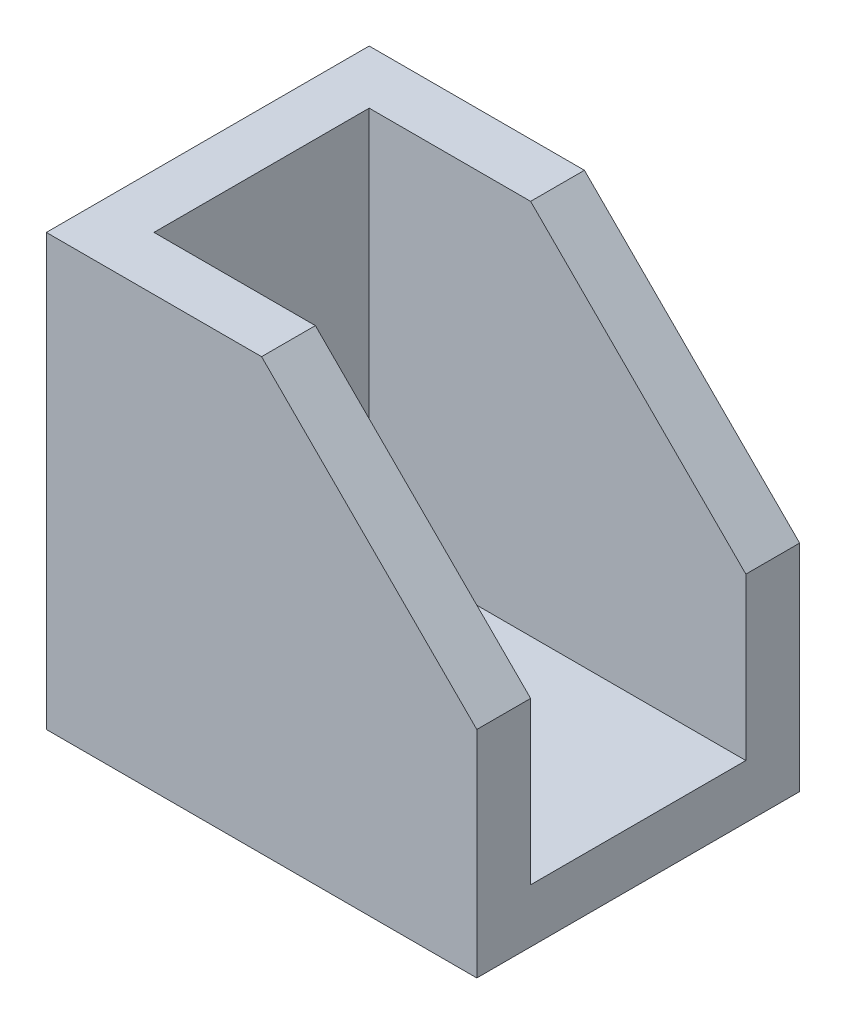
from build123d import *

# Parameters (mm, degrees)
BOSS_EXTRUDE1_DEPTH = 15
SKETCH2_W           = 10
SKETCH2_H           = 2.5
SKETCH2_H_2         = 7.5
CUT_EXTRUDE2_DEPTH  = 17.5


with BuildPart() as part:
    # Sketch1 → Boss-Extrude1 (new body)
    with BuildSketch(Plane.XY):
        Polygon((0, 0), (0, 20), (10, 20), (20, 10), (20, 0), align=None)
    extrude(amount=BOSS_EXTRUDE1_DEPTH)

    # Sketch2 → Cut-Extrude2 (cut)
    with BuildSketch(Plane(origin=(20, 0, 0), x_dir=(0, 0, -1), z_dir=(1, 0, 0))):
        with Locations((-7.5, 18.75)):
            Rectangle(SKETCH2_W, SKETCH2_H)
        with Locations((-7.5, 13.75)):
            Rectangle(SKETCH2_W, SKETCH2_H_2)
        with Locations((-7.5, 6.25)):
            Rectangle(SKETCH2_W, SKETCH2_H_2)
    extrude(amount=-CUT_EXTRUDE2_DEPTH, mode=Mode.SUBTRACT)


solid = part.part
